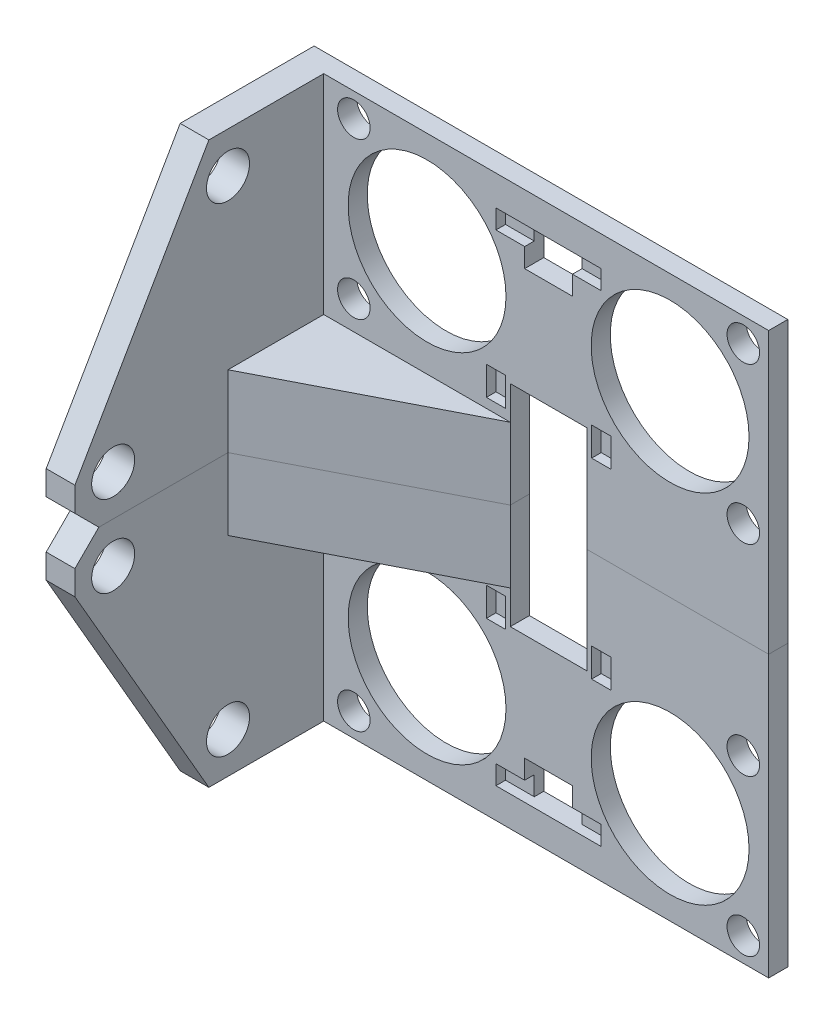
from build123d import *

# Parameters (mm, degrees)
SKETCH_1_W          = 46
SKETCH_1_H          = 21.3
EXTRUDE_1_DEPTH     = 2
SKETCH_2_R          = 8.25
CUT_EXTRUDE_1_DEPTH = 26.424840216
SKETCH_3_W          = 8
SKETCH_3_H          = 3
CUT_EXTRUDE_2_DEPTH = 26.424840216
SKETCH_4_W          = 5
SKETCH_4_H          = 4
CUT_EXTRUDE_3_DEPTH = 26.424840216
SKETCH_5_W          = 3
SKETCH_5_H          = 2
SKETCH_5_W_2        = 2
SKETCH_5_H_2        = 3
CUT_EXTRUDE_4_DEPTH = 1
HOLE_WIZARD_M3_1_D  = 3.4
SKETCH_9_W          = 46
SKETCH_9_H          = 2
EXTRUDE_3_DEPTH     = 8
SKETCH_10_W         = 8
SKETCH_10_H         = 8
CUT_EXTRUDE_5_DEPTH = 30.678653945
SKETCH_11_W         = 2
SKETCH_11_H         = 29.3
EXTRUDE_4_DEPTH     = 0.5
SKETCH_12_W         = 3
SKETCH_12_H         = 29.3
EXTRUDE_5_DEPTH     = 28
HOLE_WIZARD_M4_1_D  = 4.5
CHAMFER_1_SIZE      = 14
CHAMFER_1_SIZE2     = 24.248711306
CHAMFER_2_SIZE      = 2.5
RIB_1_REACH         = 50.423
SKETCH_16_WALL_W    = 120.75963785
SKETCH_16_WALL_H    = 7.5


with BuildPart() as part:
    # 草圖1 → 填料-伸長1 (new body)
    with BuildSketch(Plane.XY):
        Rectangle(SKETCH_1_W, SKETCH_1_H)
    extrude(amount=EXTRUDE_1_DEPTH)

    # 草圖2 → 除料-伸長1 (cut, through all)
    with BuildSketch(Plane.XY.offset(2)):
        with Locations((-12.7, 0)):
            Circle(SKETCH_2_R)
        with Locations((12.7, 0)):
            Circle(SKETCH_2_R)
    extrude(amount=-CUT_EXTRUDE_1_DEPTH, mode=Mode.SUBTRACT)

    # 草圖3 → 除料-伸長2 (cut, through all)
    with BuildSketch(Plane.XY.offset(2)):
        with Locations((0, 9.15)):
            Rectangle(SKETCH_3_W, SKETCH_3_H)
    extrude(amount=-CUT_EXTRUDE_2_DEPTH, mode=Mode.SUBTRACT)

    # 草圖4 → 除料-伸長3 (cut, through all)
    with BuildSketch(Plane.XY.offset(2)):
        with Locations((0, -5.5)):
            Rectangle(SKETCH_4_W, SKETCH_4_H)
    extrude(amount=-CUT_EXTRUDE_3_DEPTH, mode=Mode.SUBTRACT)

    # 草圖5 → 除料-伸長4 (cut)
    with BuildSketch(Plane.XY.offset(2)):
        with Locations((4, -6.5)):
            Rectangle(SKETCH_5_W, SKETCH_5_H)
        with Locations((-5.5, 8.65)):
            Rectangle(SKETCH_5_W_2, SKETCH_5_H_2)
        with Locations((5.5, 8.65)):
            Rectangle(SKETCH_5_W_2, SKETCH_5_H_2)
        with Locations((-4, -6.5)):
            Rectangle(SKETCH_5_W, SKETCH_5_H)
    extrude(amount=-CUT_EXTRUDE_4_DEPTH, mode=Mode.SUBTRACT)

    # M3 餘隙孔1 (through all)
    with Locations(Plane.XY.offset(2)):
        with Locations((20.35, 8.15), (-20.35, -8.15), (-20.35, 8.15), (20.35, -8.15)):
            Hole(HOLE_WIZARD_M3_1_D / 2)

    # 草圖9 → 填料-伸長3 (add)
    with BuildSketch(Plane(origin=(0, 10.65, 0), x_dir=(1, 0, 0), z_dir=(0, 1, 0))):
        with Locations((0, -1)):
            Rectangle(SKETCH_9_W, SKETCH_9_H)
    extrude(amount=EXTRUDE_3_DEPTH)

    # 草圖10 → 除料-伸長5 (cut, through all)
    with BuildSketch(Plane.XY.offset(2)):
        with Locations((0, 14.65)):
            Rectangle(SKETCH_10_W, SKETCH_10_H)
    extrude(amount=-CUT_EXTRUDE_5_DEPTH, mode=Mode.SUBTRACT)

    # 草圖11 → 填料-伸長4 (add)
    with BuildSketch(Plane.ZY.offset(23)):
        with Locations((1, 4)):
            Rectangle(SKETCH_11_W, SKETCH_11_H)
    extrude(amount=EXTRUDE_4_DEPTH)

    # 草圖12 → 填料-伸長5 (add)
    with BuildSketch(Plane.XY):
        with Locations((-25, 4)):
            Rectangle(SKETCH_12_W, SKETCH_12_H)
    extrude(amount=EXTRUDE_5_DEPTH)

    # M4 餘隙孔1 (through all)
    with Locations(Plane(origin=(-23.5, 0, 0), x_dir=(0, 0, -1), z_dir=(1, 0, 0))):
        with Locations((-24, 14.392304845), (-12, -6.392304845)):
            Hole(HOLE_WIZARD_M4_1_D / 2)

    # 導角1
    chamfer_1_edges = [part.edges().sort_by_distance(p)[0] for p in [
        (-25, -10.65, 28),
    ]]
    chamfer_1_side = [part.faces().sort_by_distance(p)[0] for p in [
        (22.431295331, -10.65, 1),
    ]]
    chamfer(chamfer_1_edges, length=CHAMFER_1_SIZE, length2=CHAMFER_1_SIZE2, reference=chamfer_1_side[0])

    # 導角2
    chamfer_2_edges = [part.edges().sort_by_distance(p)[0] for p in [
        (-25, 18.65, 28),
    ]]
    chamfer(chamfer_2_edges, length=CHAMFER_2_SIZE)

    # 草圖16 wall → 肋材1 (add, up to next)
    with BuildSketch(Plane(origin=(-13.75, 18.65, 7), x_dir=(0.889817462813, 0, -0.456316647596), z_dir=(-0.456316647596, 0, -0.889817462813)), mode=Mode.PRIVATE) as rib_1_sk1:
        with Locations((0, 3.75)):
            Rectangle(SKETCH_16_WALL_W, SKETCH_16_WALL_H)
    rib_1_tool1 = extrude(rib_1_sk1.sketch, amount=RIB_1_REACH, mode=Mode.PRIVATE) - part.part
    add(rib_1_tool1.solids().sort_by_distance((-13.75, 18.65, 7))[0])


with BuildPart() as body_2:
    # 鏡射1: mirrored copy
    add(part.part.mirror(Plane.ZX.offset(18.65)))


solid = Compound([part.part, body_2.part])
